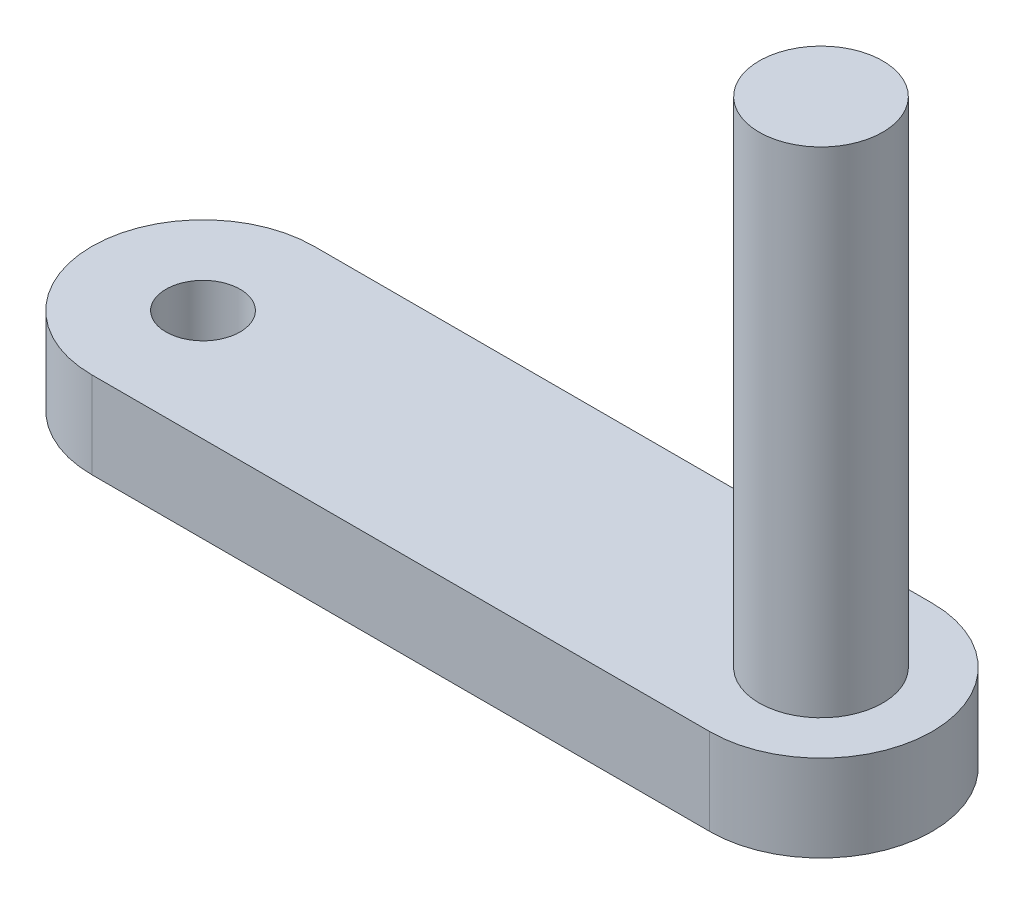
from build123d import *

# Parameters (mm, degrees)
SKETCH1_R           = 4
SKETCH1_R_2         = 3
BOSS_EXTRUDE1_DEPTH = 7
SKETCH2_R           = 5
BOSS_EXTRUDE2_DEPTH = 40


with BuildPart() as part:
    # Sketch1 → Boss-Extrude1 (new body)
    with BuildSketch(Plane(origin=(0, 0, 0), x_dir=(1, 0, 0), z_dir=(0, 1, 0))):
        with BuildLine():
            Line((-25, 9), (25, 9))
            ThreePointArc((25, 9), (34, 0), (25, -9))
            Line((25, -9), (-25, -9))
            ThreePointArc((-25, -9), (-34, 0), (-25, 9))
        make_face()
        with Locations(Location((25, 0, 0), (0, 0, 270))):  # turned: the seam where the file's is
            Circle(SKETCH1_R, mode=Mode.SUBTRACT)
        with Locations(Location((-25, 0, 0), (0, 0, 270))):  # turned: the seam where the file's is
            Circle(SKETCH1_R_2, mode=Mode.SUBTRACT)
    extrude(amount=BOSS_EXTRUDE1_DEPTH)

    # Sketch2 → Boss-Extrude2 (add)
    with BuildSketch(Plane(origin=(0, 7, 0), x_dir=(1, 0, 0), z_dir=(0, 1, 0))):
        with Locations(Location((25, 0, 0), (0, 0, 270))):  # turned: the seam where the file's is
            Circle(SKETCH2_R)
    extrude(amount=BOSS_EXTRUDE2_DEPTH)


solid = part.part
